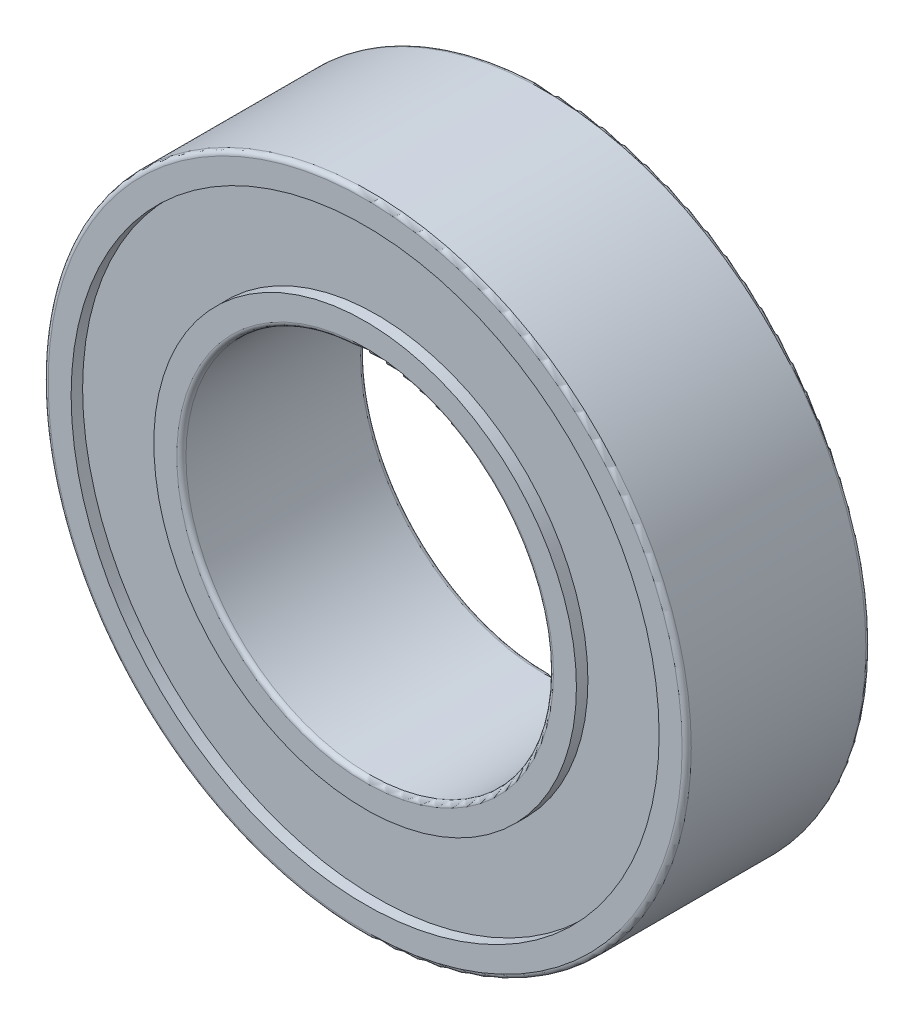
from build123d import *

# Parameters (mm, degrees)
SKETCH1_R           = 7
SKETCH1_R_2         = 4
BOSS_EXTRUDE1_DEPTH = 4
SKETCH2_R           = 6.4
SKETCH2_R_2         = 4.6
CUT_EXTRUDE1_DEPTH  = 0.25
SKETCH3_R           = 6.4
SKETCH3_R_2         = 4.6
CUT_EXTRUDE2_DEPTH  = 0.25
FILLET1_R           = 0.1
FILLET2_R           = 0.1


with BuildPart() as part:
    # Sketch1 → Boss-Extrude1 (new body)
    with BuildSketch(Plane.XY):
        Circle(SKETCH1_R)
        Circle(SKETCH1_R_2, mode=Mode.SUBTRACT)
    extrude(amount=BOSS_EXTRUDE1_DEPTH)

    # Sketch2 → Cut-Extrude1 (cut)
    with BuildSketch(Plane.XY.offset(4)):
        Circle(SKETCH2_R)
        Circle(SKETCH2_R_2, mode=Mode.SUBTRACT)
    extrude(amount=-CUT_EXTRUDE1_DEPTH, mode=Mode.SUBTRACT)

    # Sketch3 → Cut-Extrude2 (cut)
    with BuildSketch(Plane(origin=(0, 0, 0), x_dir=(-1, 0, 0), z_dir=(0, 0, -1))):
        Circle(SKETCH3_R)
        Circle(SKETCH3_R_2, mode=Mode.SUBTRACT)
    extrude(amount=-CUT_EXTRUDE2_DEPTH, mode=Mode.SUBTRACT)

    # Fillet1
    fillet1_edges = [part.edges().sort_by_distance(p)[0] for p in [
        (-7, 0, 0),
        (-7, 0, 4),
    ]]
    fillet(fillet1_edges, radius=FILLET1_R)

    # Fillet2
    fillet2_edges = [part.edges().sort_by_distance(p)[0] for p in [
        (-4, 0, 0),
        (-4, 0, 4),
    ]]
    fillet(fillet2_edges, radius=FILLET2_R)


solid = part.part
